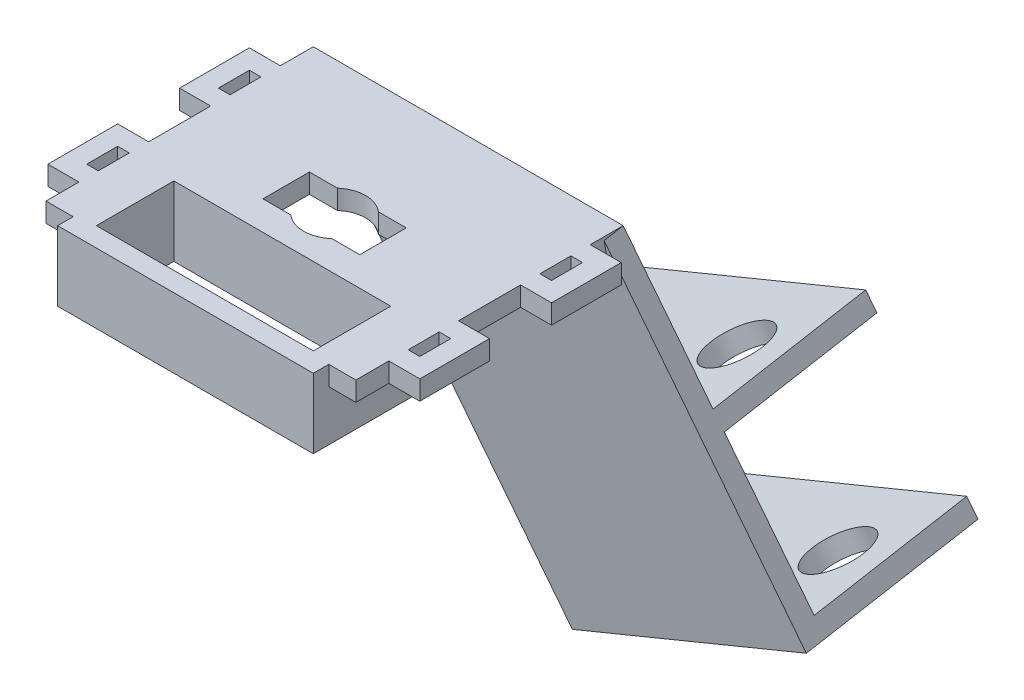
from build123d import *

# Parameters (mm, degrees)
SKETCH1_W            = 50.8
SKETCH1_H            = 43.815
SKETCH1_W_2          = 15.875
SKETCH1_H_2          = 7.62
SKETCH1_W_3          = 35.56
SKETCH1_H_3          = 5.08
BOSS_EXTRUDE1_DEPTH  = 3.175
SKETCH2_W            = 50.8
SKETCH2_H            = 43.815
SKETCH2_W_2          = 44.45
SKETCH2_H_2          = 37.465
BOSS_EXTRUDE2_DEPTH  = 8.255
SKETCH3_W            = 41.91
SKETCH3_H            = 2.54
BOSS_EXTRUDE3_DEPTH  = 11.43
SKETCH4_W            = 35.56
SKETCH4_H            = 2.54
CUT_EXTRUDE1_DEPTH   = 8.255
BOSS_EXTRUDE4_DEPTH  = 3.175
MIRROR2_COPY_1_DEPTH = 3.175
SKETCH7_W            = 15.875
SKETCH7_H            = 7.62
BOSS_EXTRUDE5_DEPTH  = 8.255
CUT_EXTRUDE2_START   = -11.43
CUT_EXTRUDE2_DEPTH   = 8.255
BOSS_EXTRUDE6_DEPTH  = 3.175
BOSS_EXTRUDE7_DEPTH  = 46.040436
SKETCH12_R           = 5.08
CUT_EXTRUDE3_DEPTH   = 54.813285309
SKETCH13_R           = 5.08
CUT_EXTRUDE4_DEPTH   = 71.721858561


with BuildPart() as part:
    # Sketch1 → Boss-Extrude1 (new body)
    with BuildSketch(Plane(origin=(0, 0, 0), x_dir=(1, 0, 0), z_dir=(0, 1, 0))):
        Rectangle(SKETCH1_W, SKETCH1_H)
        Rectangle(SKETCH1_W_2, SKETCH1_H_2, mode=Mode.SUBTRACT)
        with Locations((0, -11.1125)):
            Rectangle(SKETCH1_W_3, SKETCH1_H_3, mode=Mode.SUBTRACT)
    extrude(amount=BOSS_EXTRUDE1_DEPTH)

    # Sketch2 → Boss-Extrude2 (add)
    with BuildSketch(Plane(origin=(0, 3.175, 0), x_dir=(1, 0, 0), z_dir=(0, 1, 0))):
        Rectangle(SKETCH2_W, SKETCH2_H)
        Rectangle(SKETCH2_W_2, SKETCH2_H_2, mode=Mode.SUBTRACT)
    extrude(amount=BOSS_EXTRUDE2_DEPTH)

    # Sketch3 → Boss-Extrude3 (add)
    with BuildSketch(Plane(origin=(0, 11.43, 0), x_dir=(1, 0, 0), z_dir=(0, 1, 0))):
        with Locations((0, -23.1775)):
            Rectangle(SKETCH3_W, SKETCH3_H)
    extrude(amount=-BOSS_EXTRUDE3_DEPTH)

    # Sketch4 → Cut-Extrude1 (cut)
    with BuildSketch(Plane(origin=(0, 11.43, 0), x_dir=(1, 0, 0), z_dir=(0, 1, 0))):
        with Locations((0, -20.0025)):
            Rectangle(SKETCH4_W, SKETCH4_H)
    extrude(amount=-CUT_EXTRUDE1_DEPTH, mode=Mode.SUBTRACT)

    # Sketch5 → Boss-Extrude4 (add)
    with BuildSketch(Plane(origin=(0, 11.43, 0), x_dir=(1, 0, 0), z_dir=(0, 1, 0))):
        Polygon((-25.4, -16.51), (-30.48, -16.51), (-30.48, -5.08), (-25.4, -5.08), (-25.4, -8.255), (-27.305, -8.255), (-27.305, -13.335), (-25.4, -13.335), align=None)
    boss_extrude4 = extrude(amount=-BOSS_EXTRUDE4_DEPTH)

    # Mirror1: Boss-Extrude4 across plane
    add(boss_extrude4.mirror(Plane.XY))

    # Mirror2: Boss-Extrude4 across plane
    add(boss_extrude4.mirror(Plane(origin=(0, 0, 0), x_dir=(0, 0, 1), z_dir=(1, 0, 0))))

    # Mirror2 copy 1 sketch → Mirror2 copy 1 (add)
    with BuildSketch(Plane(origin=(0, 11.43, 0), x_dir=(-1, 0, 0), z_dir=(0, 1, 0))):
        Polygon((-25.4, -16.51), (-30.48, -16.51), (-30.48, -5.08), (-25.4, -5.08), (-25.4, -8.255), (-27.305, -8.255), (-27.305, -13.335), (-25.4, -13.335), align=None)
    extrude(amount=-MIRROR2_COPY_1_DEPTH)

    # Sketch7 → Boss-Extrude5 (add)
    with BuildSketch(Plane(origin=(0, 3.175, 0), x_dir=(1, 0, 0), z_dir=(0, 1, 0))):
        Polygon((-22.225, -18.7325), (-17.78, -18.7325), (-17.78, -8.5725), (17.78, -8.5725), (17.78, -18.7325), (22.225, -18.7325), (22.225, 18.7325), (-22.225, 18.7325), align=None)
        Rectangle(SKETCH7_W, SKETCH7_H, mode=Mode.SUBTRACT)
    extrude(amount=BOSS_EXTRUDE5_DEPTH)

    # Sketch8 → Cut-Extrude2 (cut)
    with BuildSketch(Plane(origin=(0, 11.43, 0), x_dir=(1, 0, 0), z_dir=(0, 1, 0)).offset(CUT_EXTRUDE2_START)):
        Polygon((-25.4, 21.9075), (-25.4, -21.9075), (-20.955, -21.9075), (-20.955, -5.3975), (20.955, -5.3975), (20.955, -21.9075), (25.4, -21.9075), (25.4, 21.9075), align=None)
    extrude(amount=CUT_EXTRUDE2_DEPTH, mode=Mode.SUBTRACT)

    # Sketch10 → Boss-Extrude6 (add)
    with BuildSketch(Plane(origin=(0, 4.091059817, -23.201553164), x_dir=(-1, 0, 0), z_dir=(0, 0.173648178, -0.984807753))):
        Polygon((-25.4, 7.452155165), (-36.134503848, -15.568062626), (5.592301438, -35.025591481), (25.4, 7.452155165), align=None)
    extrude(amount=-BOSS_EXTRUDE6_DEPTH)

    # Sketch11 → Boss-Extrude7 (add)
    with BuildSketch(Plane(origin=(23.71774367, 10.891742818, 1.920508126), x_dir=(0.06669094, 0.03062604, -0.997303547), z_dir=(0.906307787, 0.416197741, 0.073386891))):
        Polygon((24.765441235, -25.795675729), (29.775724817, -57.147861593), (57.992692094, -52.638606369), (57.491663736, -49.503387783), (32.409915045, -53.511614648), (28.401688179, -28.429865957), (53.48343687, -24.421639092), (52.982408512, -21.286420505), align=None)
    extrude(amount=-BOSS_EXTRUDE7_DEPTH)

    # Sketch12 → Cut-Extrude3 (cut, through all)
    with BuildSketch(Plane(origin=(12.416760179, -26.223291592, -4.623873831), x_dir=(0.906307787, 0.416197741, 0.073386891), z_dir=(-0.422618262, 0.892538935, 0.157378696))):
        with Locations((-9.550583138, 36.25947452)):
            Circle(SKETCH12_R)
        with Locations((15.849416862, 36.25947452)):
            Circle(SKETCH12_R)
    extrude(amount=-CUT_EXTRUDE3_DEPTH, mode=Mode.SUBTRACT)

    # Sketch13 → Cut-Extrude4 (cut, through all)
    with BuildSketch(Plane(origin=(0, 11.43, 0), x_dir=(1, 0, 0), z_dir=(0, 1, 0))):
        Circle(SKETCH13_R)
    extrude(amount=-CUT_EXTRUDE4_DEPTH, mode=Mode.SUBTRACT)


solid = part.part
